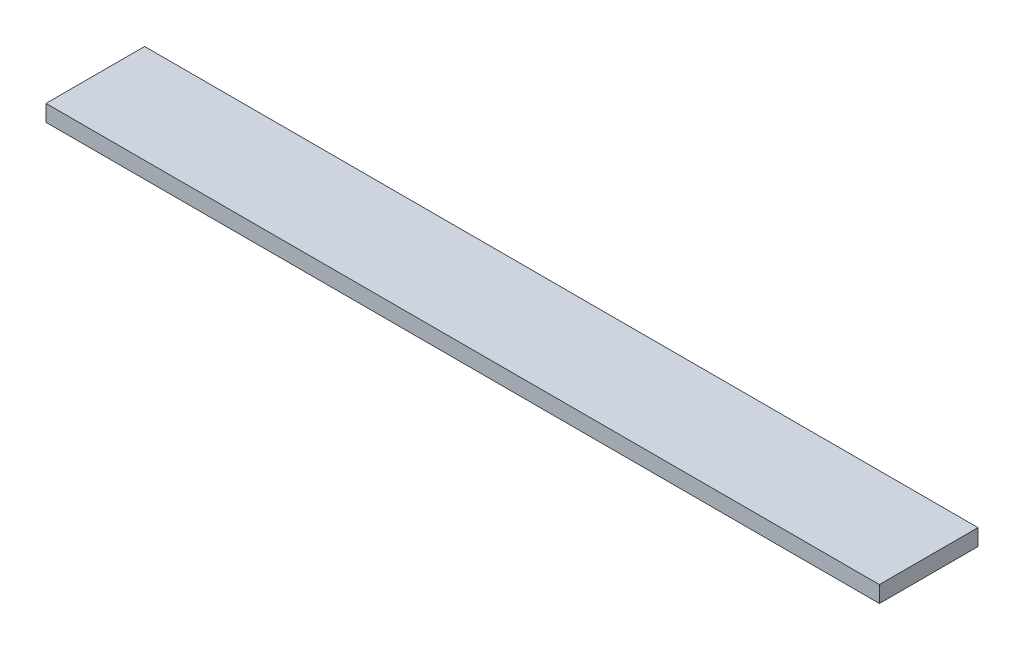
from build123d import *

# Parameters (mm, degrees)
SKETCH1_W           = 38.1
SKETCH1_H           = 6.35
BOSS_EXTRUDE1_DEPTH = 322


with BuildPart() as part:
    # Sketch1 → Boss-Extrude1 (new body)
    with BuildSketch(Plane(origin=(0, 0, 0), x_dir=(0, 0, -1), z_dir=(1, 0, 0))):
        with Locations((-19.05, -3.175)):
            Rectangle(SKETCH1_W, SKETCH1_H)
    extrude(amount=BOSS_EXTRUDE1_DEPTH)


solid = part.part
